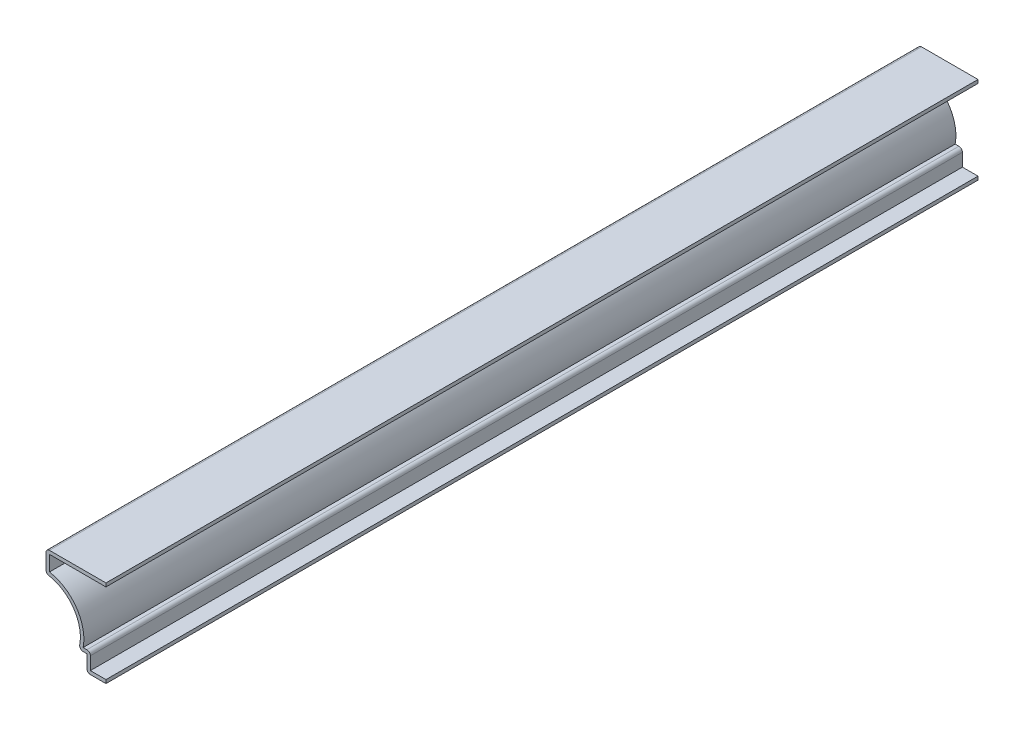
from build123d import *

# Parameters (mm, degrees)
EXTRUDE_THIN1_DEPTH = 254
FILLET1_R           = 1.016


with BuildPart() as part:
    # Sketch1 → Extrude-Thin1 (new body)
    with BuildSketch(Plane.XY):
        with BuildLine():
            Line((0, 0), (-5.55625, 0))
            Line((-5.55625, 0), (-5.55625, 4.7625))
            Line((-5.55625, 4.7625), (-7.9375, 4.7625))
            ThreePointArc((-7.9375, 4.7625), (-9.323959524, 14.156943651), (-17.4625, 19.05))
            Line((-17.4625, 19.05), (-17.4625, 25.4))
            Line((-17.4625, 25.4), (0, 25.4))
            Line((0, 25.4), (0, 24.384))
            Line((0, 24.384), (-16.4465, 24.384))
            Line((-16.4465, 24.384), (-16.4465, 19.933974896))
            ThreePointArc((-16.4465, 19.933974896), (-8.598518146, 14.89701763), (-6.645470806, 5.7785))
            Line((-6.645470806, 5.7785), (-4.54025, 5.7785))
            Line((-4.54025, 5.7785), (-4.54025, 1.016))
            Line((-4.54025, 1.016), (0, 1.016))
            Line((0, 1.016), (0, 0))
        make_face()
    extrude(amount=-EXTRUDE_THIN1_DEPTH)

    # Fillet1
    fillet1_edges = [part.edges().sort_by_distance(p)[0] for p in [
        (-4.54025, 5.7785, -127),
        (-5.55625, 0, -127),
        (-7.9375, 4.7625, -127),
        (-17.4625, 19.05, -127),
        (-17.4625, 25.4, -127),
    ]]
    fillet(fillet1_edges, radius=FILLET1_R)


solid = part.part
